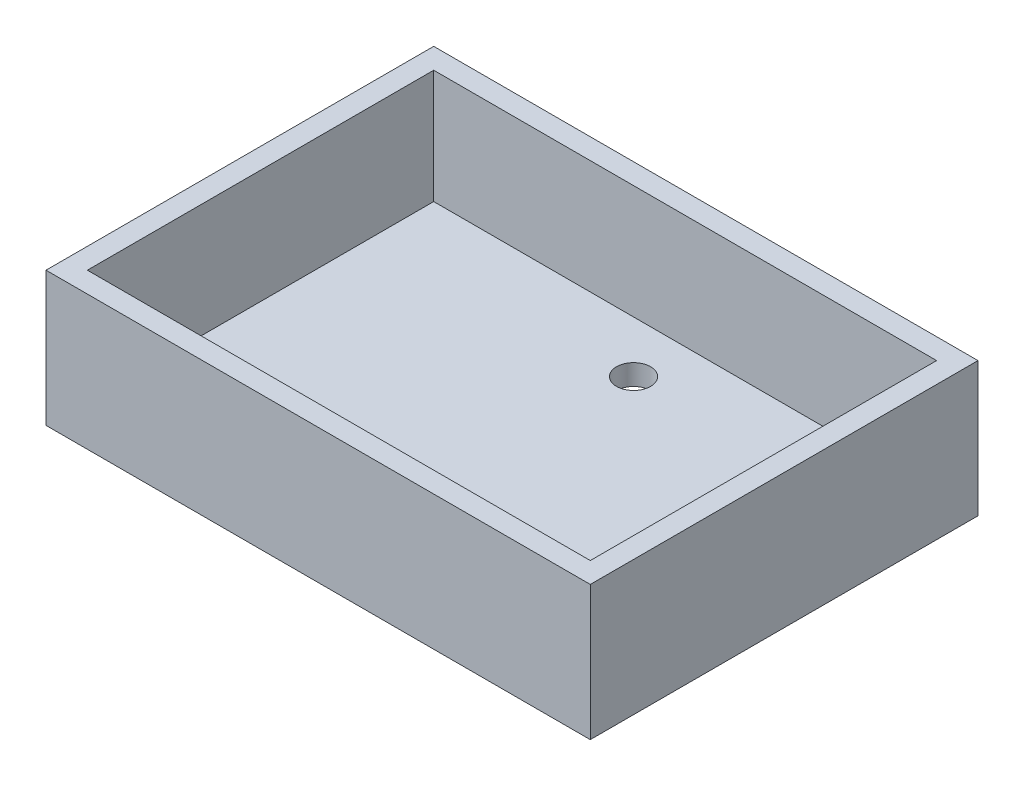
from build123d import *

# Parameters (mm, degrees)
SKETCH1_W           = 52.63
SKETCH1_H           = 37.49
SKETCH1_R           = 1.65
SKETCH1_R_2         = 1.707739437
BOSS_EXTRUDE1_DEPTH = 13
SKETCH3_W           = 48.63
SKETCH3_H           = 33.49
CUT_EXTRUDE2_DEPTH  = 11


with BuildPart() as part:
    # Sketch1 → Boss-Extrude1 (new body)
    with BuildSketch(Plane(origin=(0, 0, 0), x_dir=(1, 0, 0), z_dir=(0, 1, 0))):
        Rectangle(SKETCH1_W, SKETCH1_H)
        with Locations((0, 11.755)):
            Circle(SKETCH1_R, mode=Mode.SUBTRACT)
        with Locations((0, -11.745)):
            Circle(SKETCH1_R_2, mode=Mode.SUBTRACT)
    extrude(amount=BOSS_EXTRUDE1_DEPTH)

    # Sketch3 → Cut-Extrude2 (cut)
    with BuildSketch(Plane(origin=(0, 13, 0), x_dir=(1, 0, 0), z_dir=(0, 1, 0))):
        Rectangle(SKETCH3_W, SKETCH3_H)
    extrude(amount=-CUT_EXTRUDE2_DEPTH, mode=Mode.SUBTRACT)


solid = part.part
